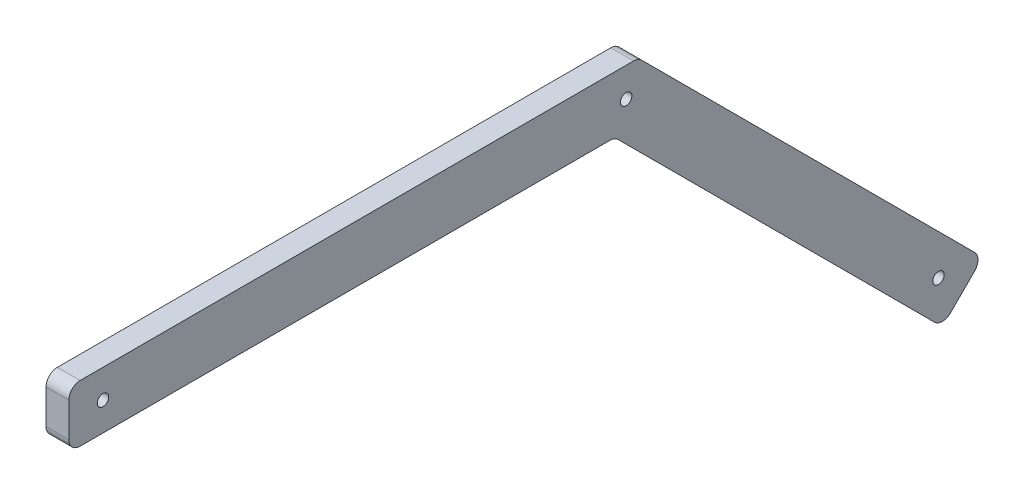
from build123d import *

# Parameters (mm, degrees)
BOSS_EXTRUDE1_DEPTH = 20
FILLET1_R           = 10
SKETCH2_R           = 5
CUT_EXTRUDE1_DEPTH  = 20
SKETCH3_R           = 5
CUT_EXTRUDE2_DEPTH  = 20
SKETCH4_R           = 5
CUT_EXTRUDE3_DEPTH  = 20


with BuildPart() as part:
    # Sketch1 → Boss-Extrude1 (new body)
    with BuildSketch(Plane(origin=(0, 0, 0), x_dir=(0, 0, -1), z_dir=(1, 0, 0))):
        Polygon((0, 0), (479.289321881, 0), (767.012334311, -287.72301243), (802.367673371, -252.367673371), (500, 50), (0, 50), align=None)
    extrude(amount=BOSS_EXTRUDE1_DEPTH)

    # Fillet1
    fillet1_edges = [part.edges().sort_by_distance(p)[0] for p in [
        (10, 0, 0),
        (10, 50, 0),
        (10, 50, -500),
        (10, -252.367673371, -802.367673371),
        (10, -287.72301243, -767.012334311),
        (10, 0, -479.289321881),
    ]]
    fillet(fillet1_edges, radius=FILLET1_R)

    # Sketch2 → Cut-Extrude1 (cut)
    with BuildSketch(Plane(origin=(20, 0, 0), x_dir=(0, 0, -1), z_dir=(1, 0, 0))):
        with Locations((30, 25)):
            Circle(SKETCH2_R)
    extrude(amount=-CUT_EXTRUDE1_DEPTH, mode=Mode.SUBTRACT)

    # Sketch3 → Cut-Extrude2 (cut)
    with BuildSketch(Plane(origin=(20, 0, 0), x_dir=(0, 0, -1), z_dir=(1, 0, 0))):
        with Locations((763.476800406, -248.832139465)):
            Circle(SKETCH3_R)
    extrude(amount=-CUT_EXTRUDE2_DEPTH, mode=Mode.SUBTRACT)

    # Sketch4 → Cut-Extrude3 (cut)
    with BuildSketch(Plane(origin=(20, 0, 0), x_dir=(0, 0, -1), z_dir=(1, 0, 0))):
        with Locations((489.329359641, 24.238795325)):
            Circle(SKETCH4_R)
    extrude(amount=-CUT_EXTRUDE3_DEPTH, mode=Mode.SUBTRACT)


solid = part.part
